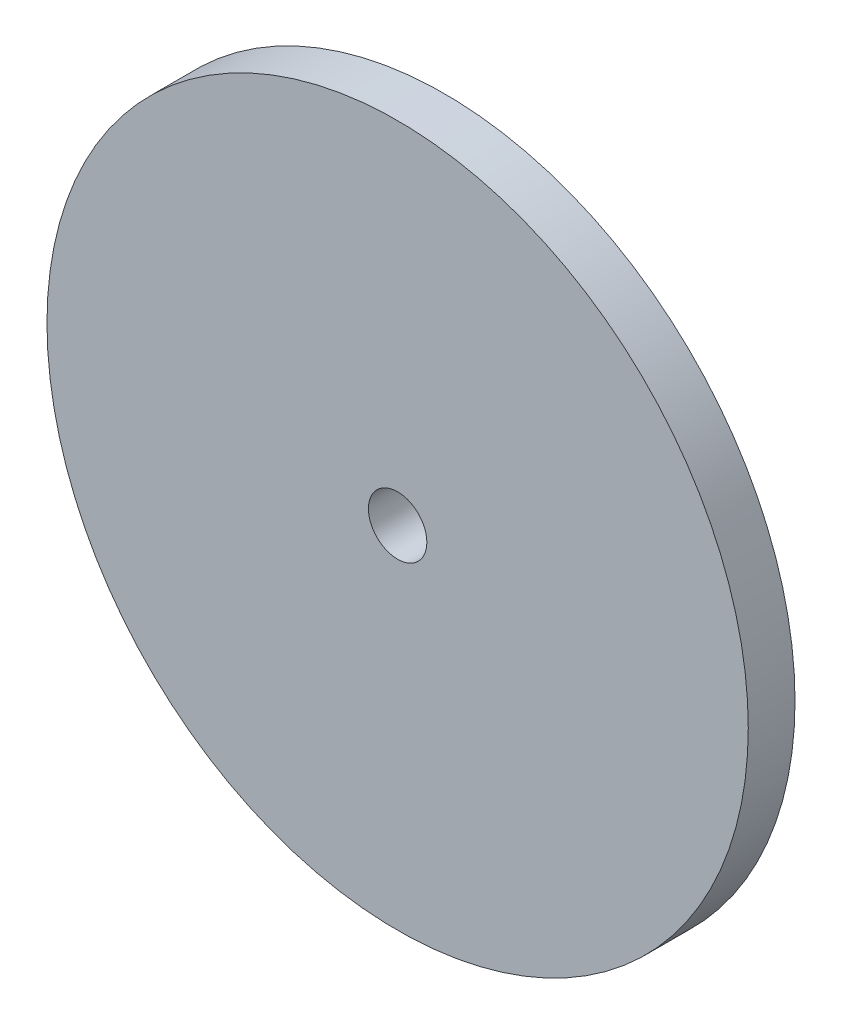
from build123d import *

# Parameters (mm, degrees)
SKETCH1_R           = 30
BOSS_EXTRUDE1_DEPTH = 4
SKETCH2_R           = 2.5
CUT_EXTRUDE1_DEPTH  = 4


with BuildPart() as part:
    # Sketch1 → Boss-Extrude1 (new body)
    with BuildSketch(Plane.XY):
        Circle(SKETCH1_R)
    extrude(amount=BOSS_EXTRUDE1_DEPTH)

    # Sketch2 → Cut-Extrude1 (cut)
    with BuildSketch(Plane.XY.offset(4)):
        Circle(SKETCH2_R)
    extrude(amount=-CUT_EXTRUDE1_DEPTH, mode=Mode.SUBTRACT)


solid = part.part
